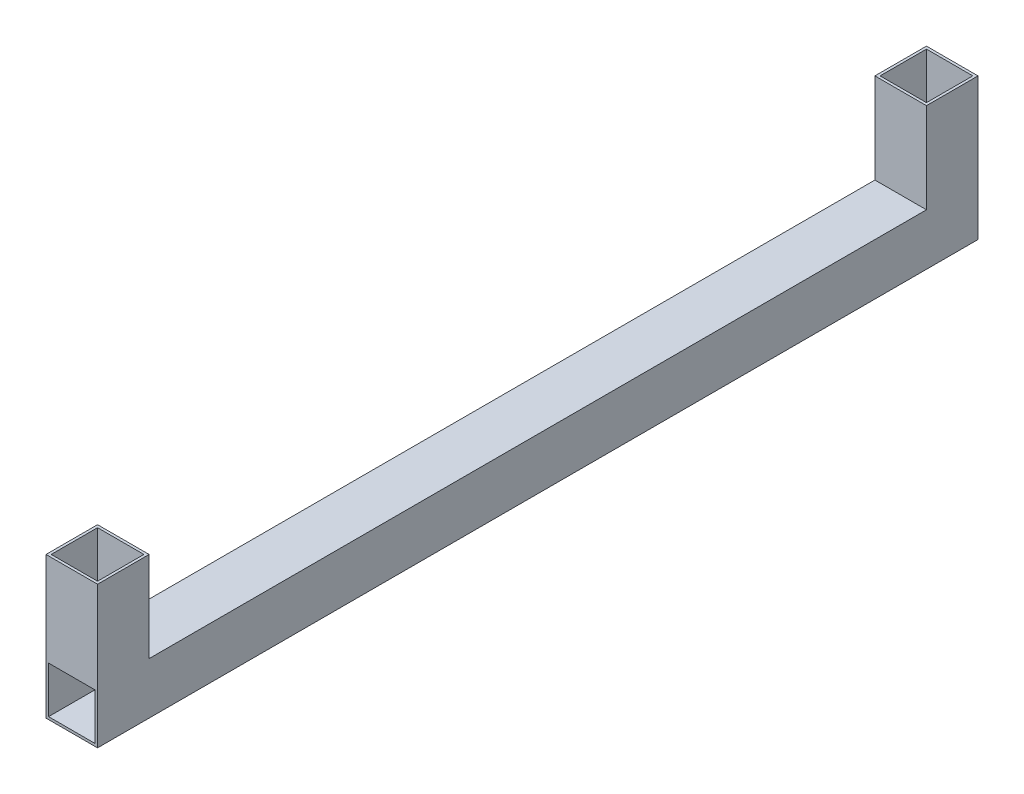
from build123d import *

# Parameters (mm, degrees)
SKETCH2_W           = 20
SKETCH2_H           = 20
SKETCH2_W_2         = 18
SKETCH2_H_2         = 18
BOSS_EXTRUDE1_DEPTH = 341.6
SKETCH3_W           = 20
SKETCH3_H           = 20
SKETCH3_W_2         = 18
SKETCH3_H_2         = 18
BOSS_EXTRUDE2_DEPTH = 35


with BuildPart() as part:
    # Sketch2 → Boss-Extrude1 (new body)
    with BuildSketch(Plane.XY):
        Rectangle(SKETCH2_W, SKETCH2_H)
        Rectangle(SKETCH2_W_2, SKETCH2_H_2, mode=Mode.SUBTRACT)
    extrude(amount=BOSS_EXTRUDE1_DEPTH)

    # Sketch3 → Boss-Extrude2 (add)
    with BuildSketch(Plane(origin=(0, 10, 0), x_dir=(1, 0, 0), z_dir=(0, 1, 0))):
        with Locations((0, -10)):
            Rectangle(SKETCH3_W, SKETCH3_H)
        with Locations((0, -10)):
            Rectangle(SKETCH3_W_2, SKETCH3_H_2, mode=Mode.SUBTRACT)
        with Locations((0, -331.6)):
            Rectangle(SKETCH3_W, SKETCH3_H)
        with Locations((0, -331.6)):
            Rectangle(SKETCH3_W_2, SKETCH3_H_2, mode=Mode.SUBTRACT)
    extrude(amount=BOSS_EXTRUDE2_DEPTH)


solid = part.part
